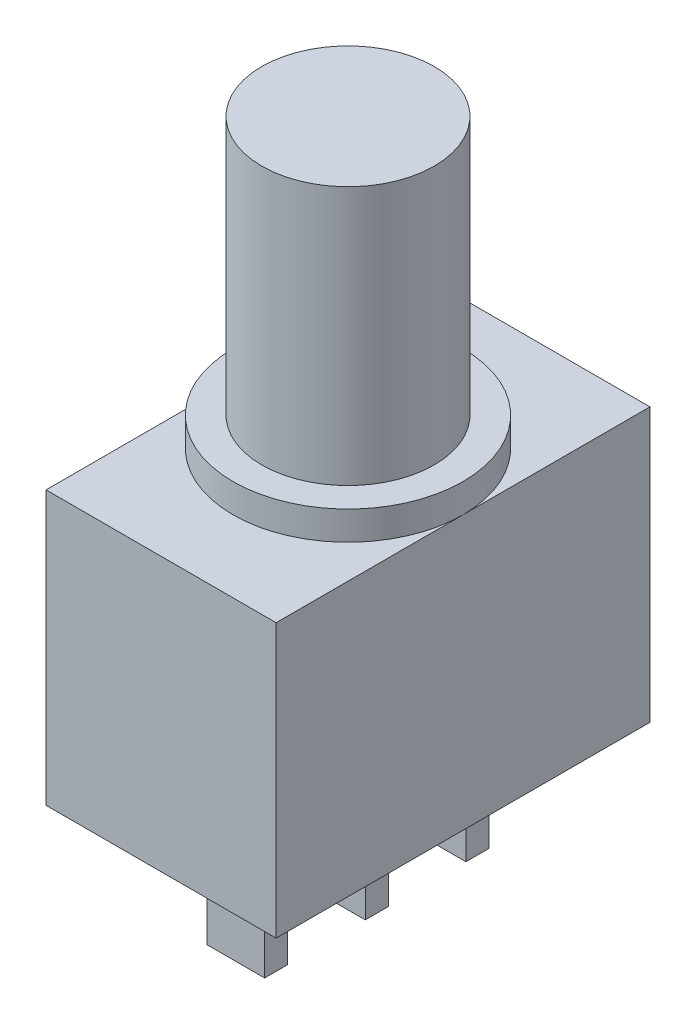
from build123d import *

# Parameters (mm, degrees)
ESQUISSE1_W        = 13
ESQUISSE1_H        = 9.5
BOSS_EXTRU_1_DEPTH = 8
ESQUISSE2_R        = 4
BOSS_EXTRU_2_DEPTH = 1
ESQUISSE3_R        = 3
BOSS_EXTRU_3_DEPTH = 9
ESQUISSE4_W        = 2
ESQUISSE4_H        = 0.8
BOSS_EXTRU_4_DEPTH = 4


with BuildPart() as part:
    # Esquisse1 → Boss.-Extru.1 (new body)
    with BuildSketch(Plane(origin=(0, 0, 0), x_dir=(0, 0, -1), z_dir=(1, 0, 0))):
        with Locations((6.5, 4.75)):
            Rectangle(ESQUISSE1_W, ESQUISSE1_H)
    extrude(amount=BOSS_EXTRU_1_DEPTH)

    # Esquisse2 → Boss.-Extru.2 (add)
    with BuildSketch(Plane(origin=(0, 9.5, 0), x_dir=(1, 0, 0), z_dir=(0, 1, 0))):
        with Locations((4, 6.5)):
            Circle(ESQUISSE2_R)
    extrude(amount=BOSS_EXTRU_2_DEPTH)

    # Esquisse3 → Boss.-Extru.3 (add)
    with BuildSketch(Plane(origin=(0, 10.5, 0), x_dir=(1, 0, 0), z_dir=(0, 1, 0))):
        with Locations((4, 6.5)):
            Circle(ESQUISSE3_R)
    extrude(amount=BOSS_EXTRU_3_DEPTH)

    # Esquisse4 → Boss.-Extru.4 (add)
    with BuildSketch(Plane.XZ):
        with Locations((4, -3)):
            Rectangle(ESQUISSE4_W, ESQUISSE4_H)
        with Locations((4, -6.5)):
            Rectangle(ESQUISSE4_W, ESQUISSE4_H)
        with Locations((4, -10)):
            Rectangle(ESQUISSE4_W, ESQUISSE4_H)
    extrude(amount=BOSS_EXTRU_4_DEPTH)


solid = part.part
